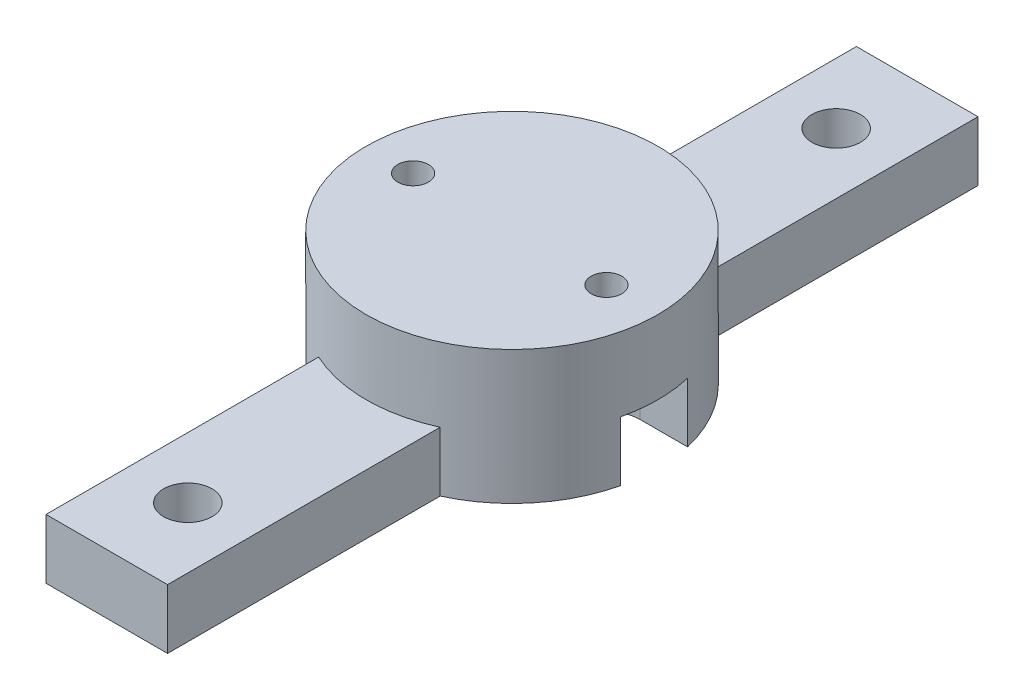
from build123d import *

# Parameters (mm, degrees)
SKETCH1_R             = 11.43
SKETCH1_R_2           = 1.2
BOSS_EXTRUDE1_DEPTH   = 5.7785
BOSS_EXTRUDE2_DEPTH   = 4.671568
F_6_CLEARANCE_HOLE1_D = 3.7973


with BuildPart() as part:
    # Sketch1 → Boss-Extrude1 (new body)
    with BuildSketch(Plane(origin=(0, 0, 0), x_dir=(1, 0, 0), z_dir=(0, 1, 0))):
        Circle(SKETCH1_R)
        with Locations((-7.75, 0)):
            Circle(SKETCH1_R_2, mode=Mode.SUBTRACT)
        with Locations((7.4, 0)):
            Circle(SKETCH1_R_2, mode=Mode.SUBTRACT)
    extrude(amount=BOSS_EXTRUDE1_DEPTH)

    # Sketch2 → Boss-Extrude2 (add)
    with BuildSketch(Plane.XZ):
        with BuildLine():
            Line((-7.75, -2.9875), (-11.032667119, -2.9875))
            ThreePointArc((-11.032667119, -2.9875), (-8.721989857, -7.387272361), (-4.7625, -10.390548289))
            Line((-4.7625, -10.390548289), (-4.7625, -31.75))
            Line((-4.7625, -31.75), (4.7625, -31.75))
            Line((4.7625, -31.75), (4.7625, -10.390548289))
            ThreePointArc((4.7625, -10.390548289), (8.837593826, -7.248574713), (11.121532887, -2.6375))
            Line((11.121532887, -2.6375), (7.4, -2.6375))
            ThreePointArc((7.4, -2.6375), (4.7625, 0), (7.4, 2.6375))
            Line((7.4, 2.6375), (11.121532887, 2.6375))
            ThreePointArc((11.121532887, 2.6375), (8.837593826, 7.248574713), (4.7625, 10.390548289))
            Line((4.7625, 10.390548289), (4.7625, 31.75))
            Line((4.7625, 31.75), (-4.7625, 31.75))
            Line((-4.7625, 31.75), (-4.7625, 10.390548289))
            ThreePointArc((-4.7625, 10.390548289), (-8.721989857, 7.387272361), (-11.032667119, 2.9875))
            Line((-11.032667119, 2.9875), (-7.75, 2.9875))
            ThreePointArc((-7.75, 2.9875), (-4.7625, 0), (-7.75, -2.9875))
        make_face()
    extrude(amount=BOSS_EXTRUDE2_DEPTH)

    # #6 Clearance Hole1 (through all)
    with Locations(Plane(origin=(0, -4.671568, 0), x_dir=(-1, 0, 0), z_dir=(0, -1, 0))):
        with Locations((0, 25.4), (0, -25.4)):
            Hole(F_6_CLEARANCE_HOLE1_D / 2)


solid = part.part
